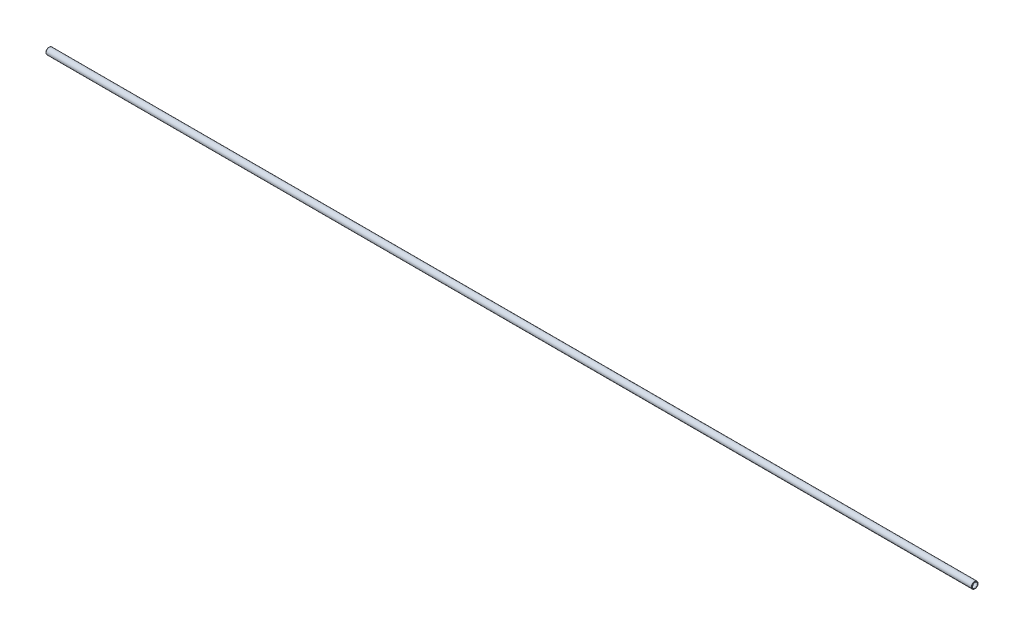
from build123d import *


with BuildPart() as part:
    # Sketch1 → Revolve1 (revolve)
    with BuildSketch(Plane.XY):
        with BuildLine():
            Line((-0.445028708, 3.689878708), (-0.2794, 3.52425))
            Line((-0.2794, 3.52425), (0, 3.52425))
            Line((0, 3.52425), (0.5588, 4.08305))
            Line((0.5588, 4.08305), (1288.2118, 4.08305))
            Line((1288.2118, 4.08305), (1288.7706, 3.52425))
            Line((1288.7706, 3.52425), (1289.05, 3.52425))
            Line((1289.05, 3.52425), (1289.215628708, 3.689878708))
            ThreePointArc((1289.215628708, 3.689878708), (1289.252826147, 3.779681269), (1289.215628708, 3.869483831))
            Line((1289.215628708, 3.869483831), (1288.689481269, 4.395631269))
            ThreePointArc((1288.689481269, 4.395631269), (1288.508193502, 4.516763883), (1288.29435, 4.5593))
            Line((1288.29435, 4.5593), (0.47625, 4.5593))
            ThreePointArc((0.47625, 4.5593), (0.262406498, 4.516763883), (0.081118731, 4.395631269))
            Line((0.081118731, 4.395631269), (-0.445028708, 3.869483831))
            ThreePointArc((-0.445028708, 3.869483831), (-0.482226147, 3.779681269), (-0.445028708, 3.689878708))
        make_face()
    revolve(axis=Axis((1288.7706, 0, 0), (-1, 0, 0)))


solid = part.part
